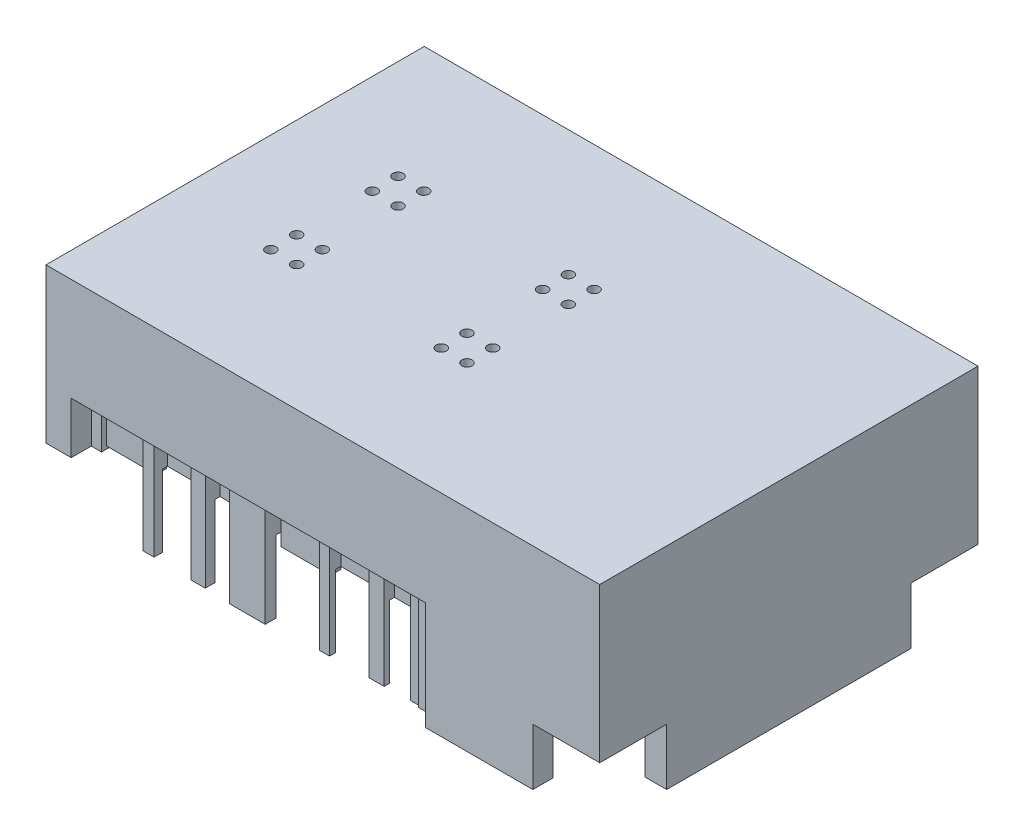
from build123d import *

# Parameters (mm, degrees)
BASE_W                            = 107.6
BASE_H                            = 73.5
BASE_EXTRUDE_DEPTH                = 10
SKETCH2_W                         = 89.7
SKETCH2_H                         = 4.9
SIDE_CUT_DEPTH                    = 131.69051228
SKETCH3_W                         = 5
SKETCH3_H                         = 47.5
FRONT_EXTRUDE_DEPTH               = 11
SKETCH4_W                         = 26.9
SKETCH4_H                         = 4.9
SKETCH4_W_2                       = 2.9
SKETCH4_H_2                       = 4.8
SKETCH4_W_3                       = 2
SKETCH4_W_4                       = 6.9
SKETCH4_W_5                       = 2.8
SKETCH4_W_6                       = 2.2
SKETCH4_W_7                       = 27.4
SKETCH4_W_8                       = 2.3
SKETCH4_W_9                       = 3
SKETCH4_W_10                      = 6.5
TERMINAL_EXTRUDES_DEPTH           = 21
SKETCH5_R                         = 1
FIBER_HOLES_DEPTH                 = 132.988673757
FIBER_HOLES_DEPTH_BACK            = 132.988673757
SKETCH6_W                         = 3.5
SKETCH6_H                         = 7
FEMALE_PIN_CONNECTORS_DEPTH       = 2.5
SKETCH10_W                        = 89.7
SKETCH10_H                        = 1
SIDE_ALTERCATION_DEPTH            = 11
SKETCH11_W                        = 0.8
SKETCH11_H                        = 47.5
FRONT_ALTERCATION_DEPTH           = 11
SKETCH13_W                        = 96.5
SKETCH13_H                        = 65.7
MASTER_DEPTH_ALTERCATION_DEPTH    = 3
SKETCH14_W                        = 91.5
SKETCH14_H                        = 53.7
CUT_WEIGHT_DEPTH                  = 4
SKETCH15_W                        = 9.6
SKETCH15_H                        = 2
COVER_GOLD_PLATE_RIGHT_SIDE_DEPTH = 2.5
SKETCH16_W                        = 9.6
SKETCH16_H                        = 2
SKETCH16_W_2                      = 9.8
GOLD_PLATE_ADJUSTMENT_DEPTH       = 2
RIGHT_START                       = -14
SKETCH17_W                        = 11.7
SKETCH17_H                        = 1.5
SKETCH17_W_2                      = 24.3
SKETCH17_H_2                      = 0.73
RIGHT_SIDE_EXTRUDE_DEPTH          = 14
SKETCH18_W                        = 5
SKETCH18_H                        = 0.73
SKETCH18_W_2                      = 3
SKETCH18_H_2                      = 2
SKETCH18_W_3                      = 7.5
SKETCH18_W_4                      = 2.3
RIGHT_SIDE_ADJUSTMENT_DEPTH       = 132.988673757
SKETCH19_W                        = 2
SKETCH19_H                        = 1.4
RIGHT_CORNER_EXTRUDE_DEPTH        = 11
SKETCH21_W                        = 6.9
SKETCH21_H                        = 3.9
RIGHT_CORNER_ADJ_DEPTH            = 132.988673757
SKETCH22_W                        = 2.2
SKETCH22_H                        = 1.8
SKETCH22_W_2                      = 2.8
SKETCH22_H_2                      = 1.55
SKETCH22_W_3                      = 2
SKETCH22_H_3                      = 2.2
SKETCH22_W_4                      = 2.9
SKETCH22_H_4                      = 2.4
LEFT_SIDE_ADJUSTMENT_DEPTH        = 132.988673757
SKETCH23_W                        = 6
SKETCH23_H                        = 21
SIDE_PANEL_ADJUST_DEPTH           = 2.7
SKETCH24_R                        = 2
SKETCH24_R_2                      = 1
PIPES_DEPTH                       = 25
SKETCH25_W                        = 107.6
SKETCH25_H                        = 73.5
EXTRA_SPACE_CREATED_DEPTH         = 20
SKETCH26_W                        = 91.5
SKETCH26_H                        = 53.7
SKETCH26_R                        = 1
EXTRA_SPACE_DEPTH                 = 20
SKETCH29_R                        = 2
SKETCH29_R_2                      = 1
BOSS_EXTRUDE7_DEPTH               = 10
SKETCH30_W                        = 73.5
SKETCH30_H                        = 20
CUT_EXTRUDE10_DEPTH               = 100
SKETCH31_R                        = 1
CUT_EXTRUDE11_DEPTH               = 132.988673757
SKETCH32_W                        = 12.8
SKETCH32_H                        = 0.4
CUT_EXTRUDE12_DEPTH               = 21
SKETCH33_W                        = 6.5
SKETCH33_H                        = 2.3
CUT_EXTRUDE13_DEPTH               = 21
SKETCH34_W                        = 2
SKETCH34_H                        = 1.4
TO_LEFT_BOTTOM_DEPTH              = 21
SKETCH35_W                        = 2
SKETCH35_H                        = 3.8
TO_RIGHT_BOTTOM_DEPTH             = 21
SKETCH37_W                        = 2.2
SKETCH37_H                        = 0.4
SKETCH37_W_2                      = 2.8
SKETCH37_W_3                      = 6.9
SKETCH37_H_2                      = 1.7
SKETCH37_W_4                      = 2
SKETCH37_W_5                      = 2.9
SKETCH37_W_6                      = 1.940920507
CUT_EXTRUDE17_DEPTH               = 21
SKETCH38_W                        = 46.5
SKETCH38_H                        = 33.7
CUT_EXTRUDE18_DEPTH               = 6


with BuildPart() as part:
    # Base → Base Extrude (new body)
    with BuildSketch(Plane(origin=(0, 0, 0), x_dir=(1, 0, 0), z_dir=(0, 1, 0))):
        with Locations((53.8, 36.75)):
            Rectangle(BASE_W, BASE_H)
    extrude(amount=BASE_EXTRUDE_DEPTH)

    # Sketch2 → Side Cut (cut, through all)
    with BuildSketch(Plane.XZ):
        with Locations((49.75, -71.05)):
            Rectangle(SKETCH2_W, SKETCH2_H)
        with Locations((49.75, -2.45)):
            Rectangle(SKETCH2_W, SKETCH2_H)
    extrude(amount=-SIDE_CUT_DEPTH, mode=Mode.SUBTRACT)

    # Sketch3 → Front Extrude (add)
    with BuildSketch(Plane(origin=(0, 0, 0), x_dir=(-1, 0, 0), z_dir=(0, -1, 0))):
        with Locations((-105.1, 36.75)):
            Rectangle(SKETCH3_W, SKETCH3_H)
    extrude(amount=FRONT_EXTRUDE_DEPTH)

    # Sketch4 → Terminal Extrudes (add)
    with BuildSketch(Plane(origin=(0, 10, 0), x_dir=(1, 0, 0), z_dir=(0, 1, 0))):
        with Locations((81.15, 2.45)):
            Rectangle(SKETCH4_W, SKETCH4_H)
        with Locations((61.35, 2.5)):
            Rectangle(SKETCH4_W_2, SKETCH4_H_2)
        with Locations((51.4, 2.5)):
            Rectangle(SKETCH4_W_3, SKETCH4_H_2)
        with Locations((37.35, 2.5)):
            Rectangle(SKETCH4_W_4, SKETCH4_H_2)
        with Locations((27.5, 2.5)):
            Rectangle(SKETCH4_W_5, SKETCH4_H_2)
        with Locations((17.6, 2.5)):
            Rectangle(SKETCH4_W_6, SKETCH4_H_2)
        with Locations((80.9, 71)):
            Rectangle(SKETCH4_W_7, SKETCH4_H_2)
        with Locations((56.25, 71)):
            Rectangle(SKETCH4_W_8, SKETCH4_H_2)
        with Locations((46.1, 71)):
            Rectangle(SKETCH4_W_9, SKETCH4_H_2)
        with Locations((36.35, 71)):
            Rectangle(SKETCH4_W_10, SKETCH4_H_2)
        with Locations((22.5, 71)):
            Rectangle(SKETCH4_W_3, SKETCH4_H_2)
        with Locations((12.9, 71)):
            Rectangle(SKETCH4_W_6, SKETCH4_H_2)
        with Locations((5.9, 2.5)):
            Rectangle(SKETCH4_W_3, SKETCH4_H_2)
        with Locations((5.9, 71)):
            Rectangle(SKETCH4_W_3, SKETCH4_H_2)
    extrude(amount=-TERMINAL_EXTRUDES_DEPTH)

    # Sketch5 → Fiber Holes (cut, two sides)
    with BuildSketch(Plane(origin=(0, 10, 0), x_dir=(1, 0, 0), z_dir=(0, 1, 0))) as fiber_holes_sk:
        with Locations(Location((24.3, 49.1, 0), (0, 0, 270))):
            Circle(SKETCH5_R)
        with Locations(Location((24.3, 44.1, 0), (0, 0, 270))):
            Circle(SKETCH5_R)
        with Locations(Location((19.3, 44.1, 0), (0, 0, 270))):
            Circle(SKETCH5_R)
        with Locations(Location((19.3, 49.1, 0), (0, 0, 270))):
            Circle(SKETCH5_R)
        with Locations(Location((52.4, 49.1, 0), (0, 0, 270))):
            Circle(SKETCH5_R)
        with Locations(Location((52.4, 44.1, 0), (0, 0, 270))):
            Circle(SKETCH5_R)
        with Locations(Location((57.4, 44.1, 0), (0, 0, 270))):
            Circle(SKETCH5_R)
        with Locations(Location((57.4, 49.1, 0), (0, 0, 270))):
            Circle(SKETCH5_R)
        with Locations(Location((57.4, 29.4, 0), (0, 0, 270))):
            Circle(SKETCH5_R)
        with Locations(Location((52.4, 29.4, 0), (0, 0, 270))):
            Circle(SKETCH5_R)
        with Locations(Location((57.4, 24.4, 0), (0, 0, 270))):
            Circle(SKETCH5_R)
        with Locations(Location((52.4, 24.4, 0), (0, 0, 270))):
            Circle(SKETCH5_R)
        with Locations(Location((24.3, 29.4, 0), (0, 0, 270))):
            Circle(SKETCH5_R)
        with Locations(Location((24.3, 24.4, 0), (0, 0, 270))):
            Circle(SKETCH5_R)
        with Locations(Location((19.3, 24.4, 0), (0, 0, 270))):
            Circle(SKETCH5_R)
        with Locations(Location((19.3, 29.4, 0), (0, 0, 270))):
            Circle(SKETCH5_R)
    extrude(amount=FIBER_HOLES_DEPTH, mode=Mode.SUBTRACT)
    extrude(fiber_holes_sk.sketch, amount=-FIBER_HOLES_DEPTH_BACK, mode=Mode.SUBTRACT)

    # Sketch6 → Female Pin Connectors (cut)
    with BuildSketch(Plane.XZ):
        with Locations((2.95, -56.3)):
            Rectangle(SKETCH6_W, SKETCH6_H)
        with Locations((2.95, -17.2)):
            Rectangle(SKETCH6_W, SKETCH6_H)
    extrude(amount=-FEMALE_PIN_CONNECTORS_DEPTH, mode=Mode.SUBTRACT)

    # Sketch10 → Side Altercation (cut)
    with BuildSketch(Plane(origin=(0, -11, 0), x_dir=(-1, 0, 0), z_dir=(0, -1, 0))):
        with Locations((-49.75, 69.1)):
            Rectangle(SKETCH10_W, SKETCH10_H)
        with Locations((-49.75, 4.4)):
            Rectangle(SKETCH10_W, SKETCH10_H)
    extrude(amount=-SIDE_ALTERCATION_DEPTH, mode=Mode.SUBTRACT)

    # Sketch11 → Front Altercation (cut)
    with BuildSketch(Plane(origin=(0, -11, 0), x_dir=(-1, 0, 0), z_dir=(0, -1, 0))):
        with Locations((-103, 36.75)):
            Rectangle(SKETCH11_W, SKETCH11_H)
    extrude(amount=-FRONT_ALTERCATION_DEPTH, mode=Mode.SUBTRACT)

    # Sketch13 → Master Depth Altercation (cut)
    with BuildSketch(Plane.XZ):
        with Locations((55.15, -36.75)):
            Rectangle(SKETCH13_W, SKETCH13_H)
    extrude(amount=-MASTER_DEPTH_ALTERCATION_DEPTH, mode=Mode.SUBTRACT)

    # Sketch14 → Cut Weight (cut)
    with BuildSketch(Plane.XZ.offset(-3)):
        with Locations((52.65, -36.75)):
            Rectangle(SKETCH14_W, SKETCH14_H)
    extrude(amount=-CUT_WEIGHT_DEPTH, mode=Mode.SUBTRACT)

    # Sketch15 → Cover Gold Plate _Right Side (add)
    with BuildSketch(Plane(origin=(0, 3, 0), x_dir=(-1, 0, 0), z_dir=(0, -1, 0))):
        with Locations((-11.7, 5.9)):
            Rectangle(SKETCH15_W, SKETCH15_H)
        with Locations((-45.6, 5.9)):
            Rectangle(SKETCH15_W, SKETCH15_H)
    extrude(amount=COVER_GOLD_PLATE_RIGHT_SIDE_DEPTH)

    # Sketch16 → Gold Plate Adjustment (add)
    with BuildSketch(Plane.XZ.offset(-3)):
        with Locations((28.3, -67.6)):
            Rectangle(SKETCH16_W, SKETCH16_H)
        with Locations((62.3, -67.6)):
            Rectangle(SKETCH16_W_2, SKETCH16_H)
    extrude(amount=GOLD_PLATE_ADJUSTMENT_DEPTH)

    # Sketch17 → Right Side Extrude (add)
    with BuildSketch(Plane.XZ.offset(11).offset(RIGHT_START)):
        with Locations((17.65, -68.85)):
            Rectangle(SKETCH17_W, SKETCH17_H)
        with Locations((45.25, -69.235)):
            Rectangle(SKETCH17_W_2, SKETCH17_H_2)
    extrude(amount=RIGHT_SIDE_EXTRUDE_DEPTH)

    # Sketch18 → Right Side Adjustment (cut, through all)
    with BuildSketch(Plane.XZ.offset(11)):
        with Locations((42.1, -69.235)):
            Rectangle(SKETCH18_W, SKETCH18_H)
        with Locations((46.1, -72.4)):
            Rectangle(SKETCH18_W_2, SKETCH18_H_2)
        with Locations((51.35, -69.235)):
            Rectangle(SKETCH18_W_3, SKETCH18_H)
        with Locations((56.25, -72.4)):
            Rectangle(SKETCH18_W_4, SKETCH18_H_2)
        Polygon((14, -73.4), (14, -69.6), (21.5, -69.6), (21.5, -73.4), (23.5, -73.4), (23.5, -69.5), (21.5, -69.5), (21.5, -68.1), (14, -68.1), (14, -69.5), (11.8, -69.5), (11.8, -73.4), align=None)
    extrude(amount=-RIGHT_SIDE_ADJUSTMENT_DEPTH, mode=Mode.SUBTRACT)

    # Sketch19 → Right Corner Extrude (add)
    with BuildSketch(Plane.XZ.offset(11)):
        with Locations((5.9, -68.8)):
            Rectangle(SKETCH19_W, SKETCH19_H)
    extrude(amount=-RIGHT_CORNER_EXTRUDE_DEPTH)

    # Sketch21 → Right Corner Adj (cut, through all)
    with BuildSketch(Plane.XZ.offset(11)):
        with Locations((3.45, -71.55)):
            Rectangle(SKETCH21_W, SKETCH21_H)
    extrude(amount=-RIGHT_CORNER_ADJ_DEPTH, mode=Mode.SUBTRACT)

    # Sketch22 → Left Side Adjustment (cut, through all)
    with BuildSketch(Plane.XZ.offset(11)):
        with Locations((17.6, -1)):
            Rectangle(SKETCH22_W, SKETCH22_H)
        with Locations((27.5, -0.875)):
            Rectangle(SKETCH22_W_2, SKETCH22_H_2)
        with Locations((51.4, -1.2)):
            Rectangle(SKETCH22_W_3, SKETCH22_H_3)
        with Locations((61.35, -1.3)):
            Rectangle(SKETCH22_W_4, SKETCH22_H_4)
    extrude(amount=-LEFT_SIDE_ADJUSTMENT_DEPTH, mode=Mode.SUBTRACT)

    # Sketch23 → Side Panel Adjust (cut)
    with BuildSketch(Plane.XY):
        with Locations((70.7, -0.5)):
            Rectangle(SKETCH23_W, SKETCH23_H)
    extrude(amount=-SIDE_PANEL_ADJUST_DEPTH, mode=Mode.SUBTRACT)

    # Sketch24 → Pipes (add)
    with BuildSketch(Plane(origin=(0, 10, 0), x_dir=(1, 0, 0), z_dir=(0, 1, 0))):
        with Locations(Location((19.3, 49.1, 0), (0, 0, 270))):
            Circle(SKETCH24_R)
        with Locations(Location((19.3, 49.1, 0), (0, 0, 270))):
            Circle(SKETCH24_R_2, mode=Mode.SUBTRACT)
        with Locations(Location((24.3, 49.1, 0), (0, 0, 270))):
            Circle(SKETCH24_R)
        with Locations(Location((24.3, 49.1, 0), (0, 0, 270))):
            Circle(SKETCH24_R_2, mode=Mode.SUBTRACT)
        with Locations(Location((19.3, 44.1, 0), (0, 0, 270))):
            Circle(SKETCH24_R)
        with Locations(Location((19.3, 44.1, 0), (0, 0, 270))):
            Circle(SKETCH24_R_2, mode=Mode.SUBTRACT)
        with Locations(Location((24.3, 44.1, 0), (0, 0, 270))):
            Circle(SKETCH24_R)
        with Locations(Location((24.3, 44.1, 0), (0, 0, 270))):
            Circle(SKETCH24_R_2, mode=Mode.SUBTRACT)
        with Locations(Location((52.4, 49.1, 0), (0, 0, 90))):
            Circle(SKETCH24_R)
        with Locations(Location((52.4, 49.1, 0), (0, 0, 270))):
            Circle(SKETCH24_R_2, mode=Mode.SUBTRACT)
        with Locations(Location((52.4, 44.1, 0), (0, 0, 90))):
            Circle(SKETCH24_R)
        with Locations(Location((52.4, 44.1, 0), (0, 0, 270))):
            Circle(SKETCH24_R_2, mode=Mode.SUBTRACT)
        with Locations(Location((57.4, 44.1, 0), (0, 0, 90))):
            Circle(SKETCH24_R)
        with Locations(Location((57.4, 44.1, 0), (0, 0, 270))):
            Circle(SKETCH24_R_2, mode=Mode.SUBTRACT)
        with Locations(Location((57.4, 49.1, 0), (0, 0, 90))):
            Circle(SKETCH24_R)
        with Locations(Location((57.4, 49.1, 0), (0, 0, 270))):
            Circle(SKETCH24_R_2, mode=Mode.SUBTRACT)
        with Locations(Location((57.4, 29.4, 0), (0, 0, 270))):
            Circle(SKETCH24_R)
        with Locations(Location((57.4, 29.4, 0), (0, 0, 270))):
            Circle(SKETCH24_R_2, mode=Mode.SUBTRACT)
        with Locations(Location((57.4, 24.4, 0), (0, 0, 270))):
            Circle(SKETCH24_R)
        with Locations(Location((57.4, 24.4, 0), (0, 0, 270))):
            Circle(SKETCH24_R_2, mode=Mode.SUBTRACT)
        with Locations(Location((52.4, 24.4, 0), (0, 0, 270))):
            Circle(SKETCH24_R)
        with Locations(Location((52.4, 24.4, 0), (0, 0, 270))):
            Circle(SKETCH24_R_2, mode=Mode.SUBTRACT)
        with Locations(Location((52.4, 29.4, 0), (0, 0, 270))):
            Circle(SKETCH24_R)
        with Locations(Location((52.4, 29.4, 0), (0, 0, 270))):
            Circle(SKETCH24_R_2, mode=Mode.SUBTRACT)
        with Locations(Location((24.3, 24.4, 0), (0, 0, 90))):
            Circle(SKETCH24_R)
        with Locations(Location((24.3, 24.4, 0), (0, 0, 270))):
            Circle(SKETCH24_R_2, mode=Mode.SUBTRACT)
        with Locations(Location((24.3, 29.4, 0), (0, 0, 90))):
            Circle(SKETCH24_R)
        with Locations(Location((24.3, 29.4, 0), (0, 0, 270))):
            Circle(SKETCH24_R_2, mode=Mode.SUBTRACT)
        with Locations(Location((19.3, 29.4, 0), (0, 0, 90))):
            Circle(SKETCH24_R)
        with Locations(Location((19.3, 29.4, 0), (0, 0, 270))):
            Circle(SKETCH24_R_2, mode=Mode.SUBTRACT)
        with Locations(Location((19.3, 24.4, 0), (0, 0, 90))):
            Circle(SKETCH24_R)
        with Locations(Location((19.3, 24.4, 0), (0, 0, 270))):
            Circle(SKETCH24_R_2, mode=Mode.SUBTRACT)
    extrude(amount=PIPES_DEPTH)

    # Sketch25 → Extra Space Created (add)
    with BuildSketch(Plane(origin=(0, 10, 0), x_dir=(1, 0, 0), z_dir=(0, 1, 0))):
        with Locations((53.8, 36.75)):
            Rectangle(SKETCH25_W, SKETCH25_H)
    extrude(amount=EXTRA_SPACE_CREATED_DEPTH)

    # Sketch26 → Extra Space (cut)
    with BuildSketch(Plane.XZ.offset(-7)):
        with Locations((52.65, -36.75)):
            Rectangle(SKETCH26_W, SKETCH26_H)
        with Locations(Location((19.3, -24.4, 0), (0, 0, 90))):
            Circle(SKETCH26_R, mode=Mode.SUBTRACT)
        with Locations(Location((24.3, -24.4, 0), (0, 0, 90))):
            Circle(SKETCH26_R, mode=Mode.SUBTRACT)
        with Locations(Location((19.3, -29.4, 0), (0, 0, 90))):
            Circle(SKETCH26_R, mode=Mode.SUBTRACT)
        with Locations(Location((24.3, -29.4, 0), (0, 0, 90))):
            Circle(SKETCH26_R, mode=Mode.SUBTRACT)
        with Locations(Location((52.4, -24.4, 0), (0, 0, 90))):
            Circle(SKETCH26_R, mode=Mode.SUBTRACT)
        with Locations(Location((57.4, -24.4, 0), (0, 0, 90))):
            Circle(SKETCH26_R, mode=Mode.SUBTRACT)
        with Locations(Location((52.4, -29.4, 0), (0, 0, 90))):
            Circle(SKETCH26_R, mode=Mode.SUBTRACT)
        with Locations(Location((57.4, -29.4, 0), (0, 0, 90))):
            Circle(SKETCH26_R, mode=Mode.SUBTRACT)
        with Locations(Location((19.3, -44.1, 0), (0, 0, 90))):
            Circle(SKETCH26_R, mode=Mode.SUBTRACT)
        with Locations(Location((24.3, -44.1, 0), (0, 0, 90))):
            Circle(SKETCH26_R, mode=Mode.SUBTRACT)
        with Locations(Location((52.4, -49.1, 0), (0, 0, 90))):
            Circle(SKETCH26_R, mode=Mode.SUBTRACT)
        with Locations(Location((52.4, -44.1, 0), (0, 0, 90))):
            Circle(SKETCH26_R, mode=Mode.SUBTRACT)
        with Locations(Location((57.4, -44.1, 0), (0, 0, 90))):
            Circle(SKETCH26_R, mode=Mode.SUBTRACT)
        with Locations(Location((57.4, -49.1, 0), (0, 0, 90))):
            Circle(SKETCH26_R, mode=Mode.SUBTRACT)
        with Locations(Location((24.3, -49.1, 0), (0, 0, 90))):
            Circle(SKETCH26_R, mode=Mode.SUBTRACT)
        with Locations(Location((19.3, -49.1, 0), (0, 0, 90))):
            Circle(SKETCH26_R, mode=Mode.SUBTRACT)
    extrude(amount=-EXTRA_SPACE_DEPTH, mode=Mode.SUBTRACT)

    # Sketch29 → Boss-Extrude7 (add)
    with BuildSketch(Plane.XZ.offset(-27)):
        with Locations(Location((24.3, -29.4, 0), (0, 0, 270))):
            Circle(SKETCH29_R)
        with Locations(Location((24.3, -29.4, 0), (0, 0, 90))):
            Circle(SKETCH29_R_2, mode=Mode.SUBTRACT)
        with Locations(Location((19.3, -29.4, 0), (0, 0, 270))):
            Circle(SKETCH29_R)
        with Locations(Location((19.3, -29.4, 0), (0, 0, 90))):
            Circle(SKETCH29_R_2, mode=Mode.SUBTRACT)
        with Locations(Location((19.3, -24.4, 0), (0, 0, 270))):
            Circle(SKETCH29_R)
        with Locations(Location((19.3, -24.4, 0), (0, 0, 90))):
            Circle(SKETCH29_R_2, mode=Mode.SUBTRACT)
        with Locations(Location((24.3, -24.4, 0), (0, 0, 270))):
            Circle(SKETCH29_R)
        with Locations(Location((24.3, -24.4, 0), (0, 0, 90))):
            Circle(SKETCH29_R_2, mode=Mode.SUBTRACT)
        with Locations(Location((57.4, -29.4, 0), (0, 0, 270))):
            Circle(SKETCH29_R)
        with Locations(Location((57.4, -29.4, 0), (0, 0, 90))):
            Circle(SKETCH29_R_2, mode=Mode.SUBTRACT)
        with Locations(Location((57.4, -24.4, 0), (0, 0, 270))):
            Circle(SKETCH29_R)
        with Locations(Location((57.4, -24.4, 0), (0, 0, 90))):
            Circle(SKETCH29_R_2, mode=Mode.SUBTRACT)
        with Locations(Location((52.4, -24.4, 0), (0, 0, 270))):
            Circle(SKETCH29_R)
        with Locations(Location((52.4, -24.4, 0), (0, 0, 90))):
            Circle(SKETCH29_R_2, mode=Mode.SUBTRACT)
        with Locations(Location((52.4, -29.4, 0), (0, 0, 270))):
            Circle(SKETCH29_R)
        with Locations(Location((52.4, -29.4, 0), (0, 0, 90))):
            Circle(SKETCH29_R_2, mode=Mode.SUBTRACT)
        with Locations(Location((19.3, -49.1, 0), (0, 0, 270))):
            Circle(SKETCH29_R)
        with Locations(Location((19.3, -49.1, 0), (0, 0, 90))):
            Circle(SKETCH29_R_2, mode=Mode.SUBTRACT)
        with Locations(Location((24.3, -49.1, 0), (0, 0, 270))):
            Circle(SKETCH29_R)
        with Locations(Location((24.3, -49.1, 0), (0, 0, 90))):
            Circle(SKETCH29_R_2, mode=Mode.SUBTRACT)
        with Locations(Location((19.3, -44.1, 0), (0, 0, 270))):
            Circle(SKETCH29_R)
        with Locations(Location((19.3, -44.1, 0), (0, 0, 90))):
            Circle(SKETCH29_R_2, mode=Mode.SUBTRACT)
        with Locations(Location((24.3, -44.1, 0), (0, 0, 270))):
            Circle(SKETCH29_R)
        with Locations(Location((24.3, -44.1, 0), (0, 0, 90))):
            Circle(SKETCH29_R_2, mode=Mode.SUBTRACT)
        with Locations(Location((57.4, -44.1, 0), (0, 0, 270))):
            Circle(SKETCH29_R)
        with Locations(Location((57.4, -44.1, 0), (0, 0, 90))):
            Circle(SKETCH29_R_2, mode=Mode.SUBTRACT)
        with Locations(Location((57.4, -49.1, 0), (0, 0, 270))):
            Circle(SKETCH29_R)
        with Locations(Location((57.4, -49.1, 0), (0, 0, 90))):
            Circle(SKETCH29_R_2, mode=Mode.SUBTRACT)
        with Locations(Location((52.4, -49.1, 0), (0, 0, 270))):
            Circle(SKETCH29_R)
        with Locations(Location((52.4, -49.1, 0), (0, 0, 90))):
            Circle(SKETCH29_R_2, mode=Mode.SUBTRACT)
        with Locations(Location((52.4, -44.1, 0), (0, 0, 270))):
            Circle(SKETCH29_R)
        with Locations(Location((52.4, -44.1, 0), (0, 0, 90))):
            Circle(SKETCH29_R_2, mode=Mode.SUBTRACT)
    extrude(amount=BOSS_EXTRUDE7_DEPTH)

    # Sketch30 → Cut-Extrude10 (cut)
    with BuildSketch(Plane.ZY):
        with Locations((-36.75, 40)):
            Rectangle(SKETCH30_W, SKETCH30_H)
    extrude(amount=-CUT_EXTRUDE10_DEPTH, mode=Mode.SUBTRACT)

    # Sketch31 → Cut-Extrude11 (cut, through all)
    with BuildSketch(Plane(origin=(0, 10, 0), x_dir=(-1, 0, 0), z_dir=(0, -1, 0))):
        with Locations(Location((-57.4, 49.1, 0), (0, 0, 90))):
            Circle(SKETCH31_R)
        with Locations(Location((-52.4, 49.1, 0), (0, 0, 90))):
            Circle(SKETCH31_R)
        with Locations(Location((-57.4, 44.1, 0), (0, 0, 90))):
            Circle(SKETCH31_R)
        with Locations(Location((-52.4, 44.1, 0), (0, 0, 90))):
            Circle(SKETCH31_R)
        with Locations(Location((-24.3, 49.1, 0), (0, 0, 90))):
            Circle(SKETCH31_R)
        with Locations(Location((-19.3, 49.1, 0), (0, 0, 90))):
            Circle(SKETCH31_R)
        with Locations(Location((-24.3, 44.1, 0), (0, 0, 90))):
            Circle(SKETCH31_R)
        with Locations(Location((-19.3, 44.1, 0), (0, 0, 90))):
            Circle(SKETCH31_R)
        with Locations(Location((-57.4, 29.4, 0), (0, 0, 90))):
            Circle(SKETCH31_R)
        with Locations(Location((-52.4, 29.4, 0), (0, 0, 90))):
            Circle(SKETCH31_R)
        with Locations(Location((-57.4, 24.4, 0), (0, 0, 90))):
            Circle(SKETCH31_R)
        with Locations(Location((-52.4, 24.4, 0), (0, 0, 90))):
            Circle(SKETCH31_R)
        with Locations(Location((-24.3, 29.4, 0), (0, 0, 90))):
            Circle(SKETCH31_R)
        with Locations(Location((-19.3, 29.4, 0), (0, 0, 90))):
            Circle(SKETCH31_R)
        with Locations(Location((-24.3, 24.4, 0), (0, 0, 90))):
            Circle(SKETCH31_R)
        with Locations(Location((-19.3, 24.4, 0), (0, 0, 90))):
            Circle(SKETCH31_R)
    extrude(amount=-CUT_EXTRUDE11_DEPTH, mode=Mode.SUBTRACT)

    # Sketch32 → Cut-Extrude12 (cut)
    with BuildSketch(Plane.XZ.offset(11)):
        with Locations((51, -71.2)):
            Rectangle(SKETCH32_W, SKETCH32_H)
    extrude(amount=-CUT_EXTRUDE12_DEPTH, mode=Mode.SUBTRACT)

    # Sketch33 → Cut-Extrude13 (cut)
    with BuildSketch(Plane.XZ.offset(11)):
        with Locations((36.35, -72.25)):
            Rectangle(SKETCH33_W, SKETCH33_H)
    extrude(amount=-CUT_EXTRUDE13_DEPTH, mode=Mode.SUBTRACT)

    # Sketch34 → To Left Bottom (cut)
    with BuildSketch(Plane(origin=(0, -11, 0), x_dir=(-1, 0, 0), z_dir=(0, -1, 0))):
        with Locations((-5.9, 68.8)):
            Rectangle(SKETCH34_W, SKETCH34_H)
    extrude(amount=-TO_LEFT_BOTTOM_DEPTH, mode=Mode.SUBTRACT)

    # Sketch35 → To Right Bottom (cut)
    with BuildSketch(Plane.XZ.offset(11)):
        with Locations((5.9, -2)):
            Rectangle(SKETCH35_W, SKETCH35_H)
    extrude(amount=-TO_RIGHT_BOTTOM_DEPTH, mode=Mode.SUBTRACT)

    # Sketch37 → Cut-Extrude17 (cut)
    with BuildSketch(Plane(origin=(0, -11, 0), x_dir=(-1, 0, 0), z_dir=(0, -1, 0))):
        with Locations((-17.6, 2.1)):
            Rectangle(SKETCH37_W, SKETCH37_H)
        with Locations((-27.5, 1.85)):
            Rectangle(SKETCH37_W_2, SKETCH37_H)
        with Locations((-37.35, 0.95)):
            Rectangle(SKETCH37_W_3, SKETCH37_H_2)
        with Locations((-51.4, 2.5)):
            Rectangle(SKETCH37_W_4, SKETCH37_H)
        with Locations((-61.35, 2.7)):
            Rectangle(SKETCH37_W_5, SKETCH37_H)
        with Locations((-68.670460254, 2.9)):
            Rectangle(SKETCH37_W_6, SKETCH37_H)
    extrude(amount=-CUT_EXTRUDE17_DEPTH, mode=Mode.SUBTRACT)

    # Sketch38 → Cut-Extrude18 (cut)
    with BuildSketch(Plane.XZ.offset(-17)):
        with Locations((40.15, -36.75)):
            Rectangle(SKETCH38_W, SKETCH38_H)
    extrude(amount=-CUT_EXTRUDE18_DEPTH, mode=Mode.SUBTRACT)


solid = part.part
